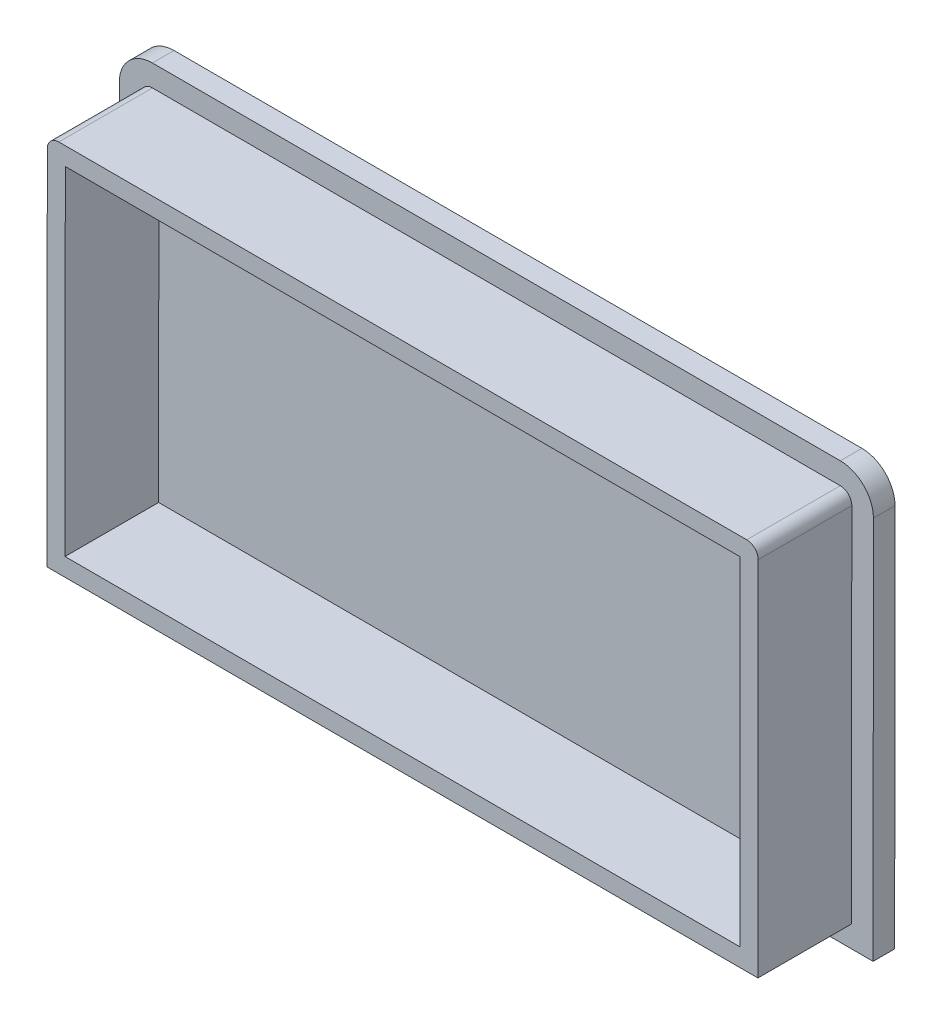
from build123d import *

# Parameters (mm, degrees)
RESSALTO_EXTRUS_O1_DEPTH = 13
RESSALTO_EXTRUS_O2_DEPTH = 3


with BuildPart() as part:
    # Esboço1 → Ressalto-extrusão1 (new body)
    with BuildSketch(Plane.XY):
        with BuildLine():
            Line((-111.248828562, 3.491171507), (-12.504488884, 3.410248792))
            Line((-12.504488884, 3.410248792), (-12.46323751, 53.746420916))
            ThreePointArc((-12.46323751, 53.746420916), (-12.930939325, 54.878175435), (-14.061925745, 55.347731606))
            Line((-14.061925745, 55.347731606), (-109.606266497, 55.426031866))
            ThreePointArc((-109.606266497, 55.426031866), (-110.738021017, 54.958330051), (-111.207577187, 53.82734363))
            Line((-111.207577187, 53.82734363), (-111.248828562, 3.491171507))
        make_face()
        Polygon((-108.746780608, 5.989121875), (-15.002439252, 5.912296746), (-14.963974236, 52.848470011), (-108.708315592, 52.92529514), align=None, mode=Mode.SUBTRACT)
    extrude(amount=RESSALTO_EXTRUS_O1_DEPTH)

    # Esboço2 → Ressalto-extrusão2 (add)
    with BuildSketch(Plane(origin=(0, 0, 0), x_dir=(-1, 0, 0), z_dir=(0, 0, -1))):
        with BuildLine():
            Line((9.463238518, 53.743962364), (9.506948443, 0.407791248))
            Line((9.506948443, 0.407791248), (114.251286106, 0.493631066))
            Line((114.251286106, 0.493631066), (114.20757618, 53.829802182))
            ThreePointArc((114.20757618, 53.829802182), (112.857602189, 57.081388141), (109.603807945, 58.426030858))
            Line((109.603807945, 58.426030858), (14.059467194, 58.347730599))
            ThreePointArc((14.059467194, 58.347730599), (10.807881235, 56.997756608), (9.463238518, 53.743962364))
        make_face()
    extrude(amount=RESSALTO_EXTRUS_O2_DEPTH)


solid = part.part
